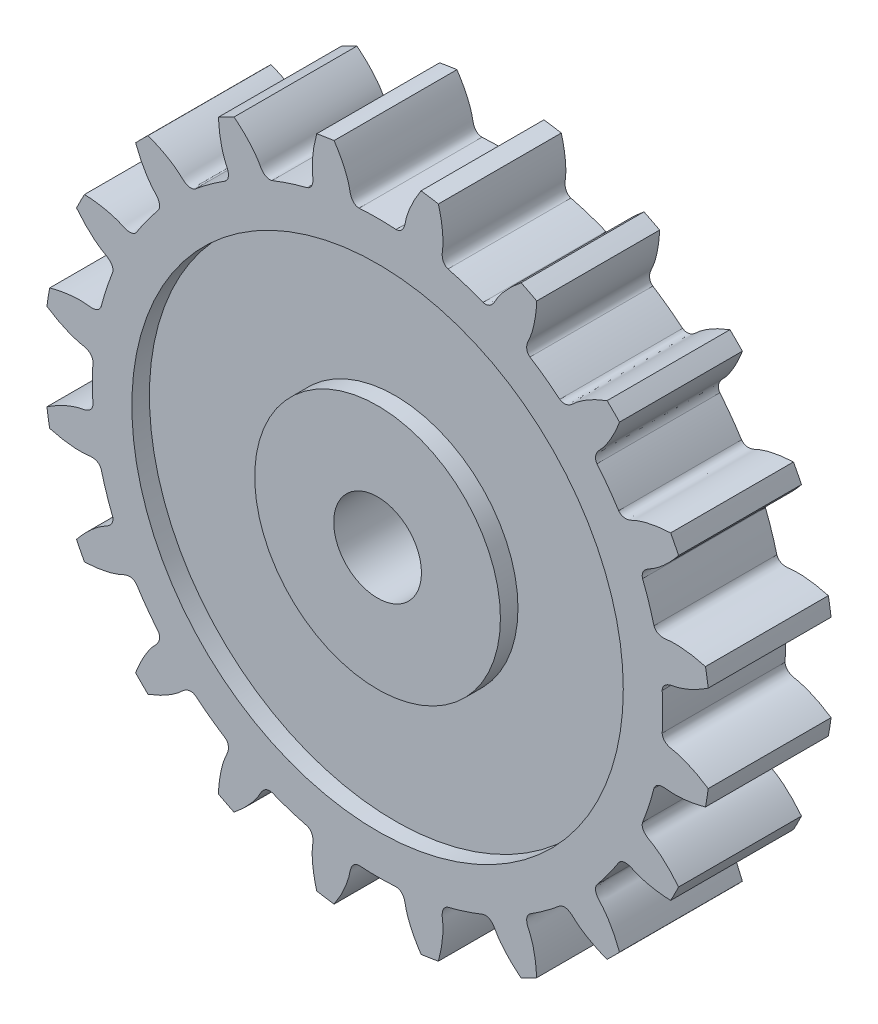
from build123d import *

# Parameters (mm, degrees)
CROQUIS1_R              = 2.5
SALIENTE_EXTRUIR1_DEPTH = 7
CROQUIS2_R              = 14
CROQUIS2_R_2            = 7
CORTAR_EXTRUIR1_DEPTH   = 1
CROQUIS3_R              = 14
CROQUIS3_R_2            = 7
CORTAR_EXTRUIR2_DEPTH   = 1


with BuildPart() as part:
    # Croquis1 → Saliente-Extruir1 (new body)
    with BuildSketch(Plane.XY):
        with BuildLine():
            ThreePointArc((6.009338484, 15.098024738), (5.021526159, 15.45466839), (4.012739321, 15.746759131))
            add(Edge.make_bspline(
                [(4.012739321, 15.746759131), (3.946115444, 15.769102329), (3.844071312, 15.832245409), (3.753150436, 15.958574818), (3.709049528, 16.068220448), (3.687336313, 16.171871712), (3.679630722, 16.27329844), (3.681699682, 16.352274965), (3.686361582, 16.409563995), (3.690140505, 16.445010565), (3.695527746, 16.484388184), (3.704084221, 16.544422236), (3.713446112, 16.632533556), (3.721941557, 16.752412041), (3.726649101, 16.89437231), (3.726023288, 17.058257781), (3.718404355, 17.243841257), (3.702184036, 17.450797585), (3.675756229, 17.678713454), (3.637539698, 17.927084936), (3.572554469, 18.265123942), (3.510335789, 18.518138446), (3.465069654, 18.681362164)],
                knots=[0.032345382, 0.032345382, 0.032345382, 0.032345382, 0.098318952, 0.140640605, 0.17619302, 0.208307484, 0.239484432, 0.271287113, 0.282206678, 0.293329329, 0.304676551, 0.319437818, 0.350137192, 0.387658647, 0.432002182, 0.483167798, 0.541155495, 0.605965273, 0.677597132, 0.756051072, 0.841327094, 1, 1, 1, 1], degree=3))
            ThreePointArc((3.465069654, 18.681362164), (2.972254836, 18.766078471), (2.477381313, 18.837796629))
            add(Edge.make_bspline(
                [(2.477381313, 18.837796629), (2.383891758, 18.696549653), (2.246532494, 18.47514519), (2.080268072, 18.173732531), (1.967170982, 17.949326772), (1.871606768, 17.740732541), (1.792227304, 17.548917731), (1.727632821, 17.374771737), (1.676394242, 17.219100778), (1.637003247, 17.082633828), (1.608038406, 16.965997377), (1.589714197, 16.879305549), (1.579300347, 16.819565676), (1.572255564, 16.780450587), (1.564895941, 16.745571144), (1.551626388, 16.689645432), (1.529188997, 16.613894949), (1.490517962, 16.519813557), (1.437837465, 16.427945099), (1.362012645, 16.337293839), (1.23650382, 16.245243527), (1.119941798, 16.216724261), (1.049674299, 16.216062527)],
                knots=[0, 0, 0, 0, 0.158672906, 0.243948928, 0.322402868, 0.394034727, 0.458844505, 0.516832202, 0.567997818, 0.612341353, 0.649862808, 0.680562182, 0.695323449, 0.706670671, 0.717793322, 0.728712887, 0.760515568, 0.791692516, 0.82380698, 0.859359395, 0.901681048, 0.967654618, 0.967654618, 0.967654618, 0.967654618], degree=3))
            ThreePointArc((1.049674299, 16.216062527), (0, 16.25), (-1.049674299, 16.216062527))
            add(Edge.make_bspline(
                [(-1.049674299, 16.216062527), (-1.119941798, 16.216724261), (-1.23650382, 16.245243527), (-1.362012645, 16.337293839), (-1.437837465, 16.427945099), (-1.490517962, 16.519813557), (-1.529188997, 16.613894949), (-1.551626388, 16.689645432), (-1.564895941, 16.745571144), (-1.572255564, 16.780450587), (-1.579300347, 16.819565676), (-1.589714197, 16.879305549), (-1.608038406, 16.965997377), (-1.637003247, 17.082633828), (-1.676394242, 17.219100778), (-1.727632821, 17.374771737), (-1.792227304, 17.548917731), (-1.871606768, 17.740732541), (-1.967170982, 17.949326772), (-2.080268072, 18.173732531), (-2.246532494, 18.47514519), (-2.383891758, 18.696549653), (-2.477381313, 18.837796629)],
                knots=[0.032345382, 0.032345382, 0.032345382, 0.032345382, 0.098318952, 0.140640605, 0.17619302, 0.208307484, 0.239484432, 0.271287113, 0.282206678, 0.293329329, 0.304676551, 0.319437818, 0.350137192, 0.387658647, 0.432002182, 0.483167798, 0.541155495, 0.605965273, 0.677597132, 0.756051072, 0.841327094, 1, 1, 1, 1], degree=3))
            ThreePointArc((-2.477381313, 18.837796629), (-2.972254836, 18.766078471), (-3.465069654, 18.681362164))
            add(Edge.make_bspline(
                [(-3.465069654, 18.681362164), (-3.510335789, 18.518138446), (-3.572554469, 18.265123942), (-3.637539698, 17.927084936), (-3.675756229, 17.678713454), (-3.702184036, 17.450797585), (-3.718404355, 17.243841257), (-3.726023288, 17.058257781), (-3.726649101, 16.89437231), (-3.721941557, 16.752412041), (-3.713446112, 16.632533556), (-3.704084221, 16.544422236), (-3.695527746, 16.484388184), (-3.690140505, 16.445010565), (-3.686361582, 16.409563995), (-3.681699682, 16.352274965), (-3.679630722, 16.27329844), (-3.687336313, 16.171871712), (-3.709049528, 16.068220448), (-3.753150436, 15.958574818), (-3.844071312, 15.832245409), (-3.946115444, 15.769102329), (-4.012739321, 15.746759131)],
                knots=[0, 0, 0, 0, 0.158672906, 0.243948928, 0.322402868, 0.394034727, 0.458844505, 0.516832202, 0.567997818, 0.612341353, 0.649862808, 0.680562182, 0.695323449, 0.706670671, 0.717793322, 0.728712887, 0.760515568, 0.791692516, 0.82380698, 0.859359395, 0.901681048, 0.967654618, 0.967654618, 0.967654618, 0.967654618], degree=3))
            ThreePointArc((-4.012739321, 15.746759131), (-5.021526159, 15.45466839), (-6.009338484, 15.098024738))
            add(Edge.make_bspline(
                [(-6.009338484, 15.098024738), (-6.076371335, 15.076940233), (-6.196041343, 15.068044021), (-6.34385244, 15.11680471), (-6.443978909, 15.179588024), (-6.522469953, 15.25068095), (-6.588321042, 15.328207665), (-6.633068455, 15.39331712), (-6.662970546, 15.442405115), (-6.680748304, 15.473303188), (-6.699535518, 15.508326891), (-6.727900314, 15.561924829), (-6.77211692, 15.638711166), (-6.835706767, 15.740688395), (-6.915340436, 15.85830369), (-7.012176192, 15.990521978), (-7.127423268, 16.136183867), (-7.26219166, 16.294080989), (-7.417537791, 16.462934926), (-7.594444709, 16.641408562), (-7.845713205, 16.876690503), (-8.044767369, 17.044812314), (-8.177328936, 17.150256309)],
                knots=[0.032345382, 0.032345382, 0.032345382, 0.032345382, 0.098318952, 0.140640605, 0.17619302, 0.208307484, 0.239484432, 0.271287113, 0.282206678, 0.293329329, 0.304676551, 0.319437818, 0.350137192, 0.387658647, 0.432002182, 0.483167798, 0.541155495, 0.605965273, 0.677597132, 0.756051072, 0.841327094, 1, 1, 1, 1], degree=3))
            ThreePointArc((-8.177328936, 17.150256309), (-8.625819495, 16.92912396), (-9.06833546, 16.696265809))
            add(Edge.make_bspline(
                [(-9.06833546, 16.696265809), (-9.06094721, 16.527042824), (-9.04193491, 16.267185101), (-8.999279738, 15.925609363), (-8.95887481, 15.677584488), (-8.913579271, 15.452656974), (-8.865052689, 15.250817455), (-8.814950277, 15.071962702), (-8.764902064, 14.915904969), (-8.716556788, 14.782347442), (-8.671432651, 14.670961465), (-8.635301069, 14.590055603), (-8.608611834, 14.535603923), (-8.591319911, 14.499818331), (-8.576772349, 14.467274391), (-8.554635334, 14.414229892), (-8.528262548, 14.339758097), (-8.504248418, 14.240914387), (-8.49286891, 14.135626425), (-8.500929004, 14.017719304), (-8.548361961, 13.869476801), (-8.625899413, 13.777890793), (-8.682358057, 13.736053238)],
                knots=[0, 0, 0, 0, 0.158672906, 0.243948928, 0.322402868, 0.394034727, 0.458844505, 0.516832202, 0.567997818, 0.612341353, 0.649862808, 0.680562182, 0.695323449, 0.706670671, 0.717793322, 0.728712887, 0.760515568, 0.791692516, 0.82380698, 0.859359395, 0.901681048, 0.967654618, 0.967654618, 0.967654618, 0.967654618], degree=3))
            ThreePointArc((-8.682358057, 13.736053238), (-9.55151035, 13.146526159), (-10.38076675, 12.502087093))
            add(Edge.make_bspline(
                [(-10.38076675, 12.502087093), (-10.438003309, 12.461320247), (-10.549067169, 12.415879381), (-10.704711757, 12.416577411), (-10.819338799, 12.445347111), (-10.915957141, 12.488705435), (-11.00254232, 12.542088616), (-11.065219567, 12.590183677), (-11.10882717, 12.62762888), (-11.135282852, 12.651521064), (-11.163973475, 12.679025017), (-11.207512672, 12.721234482), (-11.273293447, 12.780598945), (-11.365283681, 12.857934709), (-11.477364926, 12.945185345), (-11.610318901, 13.041008515), (-11.764937383, 13.143927899), (-11.941902634, 13.252451262), (-12.141824321, 13.365036305), (-12.365224184, 13.480107575), (-12.676900843, 13.626227763), (-12.9181651, 13.724609987), (-13.076822628, 13.783929409)],
                knots=[0.032345382, 0.032345382, 0.032345382, 0.032345382, 0.098318952, 0.140640605, 0.17619302, 0.208307484, 0.239484432, 0.271287113, 0.282206678, 0.293329329, 0.304676551, 0.319437818, 0.350137192, 0.387658647, 0.432002182, 0.483167798, 0.541155495, 0.605965273, 0.677597132, 0.756051072, 0.841327094, 1, 1, 1, 1], degree=3))
            ThreePointArc((-13.076822628, 13.783929409), (-13.435028843, 13.435028843), (-13.783929409, 13.076822628))
            add(Edge.make_bspline(
                [(-13.783929409, 13.076822628), (-13.724609987, 12.9181651), (-13.626227763, 12.676900843), (-13.480107575, 12.365224184), (-13.365036305, 12.141824321), (-13.252451262, 11.941902634), (-13.143927899, 11.764937383), (-13.041008515, 11.610318901), (-12.945185345, 11.477364926), (-12.857934709, 11.365283681), (-12.780598945, 11.273293447), (-12.721234482, 11.207512672), (-12.679025017, 11.163973475), (-12.651521064, 11.135282852), (-12.62762888, 11.10882717), (-12.590183677, 11.065219567), (-12.542088616, 11.00254232), (-12.488705435, 10.915957141), (-12.445347111, 10.819338799), (-12.416577411, 10.704711757), (-12.415879381, 10.549067169), (-12.461320247, 10.438003309), (-12.502087093, 10.38076675)],
                knots=[0, 0, 0, 0, 0.158672906, 0.243948928, 0.322402868, 0.394034727, 0.458844505, 0.516832202, 0.567997818, 0.612341353, 0.649862808, 0.680562182, 0.695323449, 0.706670671, 0.717793322, 0.728712887, 0.760515568, 0.791692516, 0.82380698, 0.859359395, 0.901681048, 0.967654618, 0.967654618, 0.967654618, 0.967654618], degree=3))
            ThreePointArc((-12.502087093, 10.38076675), (-13.146526159, 9.55151035), (-13.736053238, 8.682358057))
            add(Edge.make_bspline(
                [(-13.736053238, 8.682358057), (-13.777890793, 8.625899413), (-13.869476801, 8.548361961), (-14.017719304, 8.500929004), (-14.135626425, 8.49286891), (-14.240914387, 8.504248418), (-14.339758097, 8.528262548), (-14.414229892, 8.554635334), (-14.467274391, 8.576772349), (-14.499818331, 8.591319911), (-14.535603923, 8.608611834), (-14.590055603, 8.635301069), (-14.670961465, 8.671432651), (-14.782347442, 8.716556788), (-14.915904969, 8.764902064), (-15.071962702, 8.814950277), (-15.250817455, 8.865052689), (-15.452656974, 8.913579271), (-15.677584488, 8.95887481), (-15.925609363, 8.999279738), (-16.267185101, 9.04193491), (-16.527042824, 9.06094721), (-16.696265809, 9.06833546)],
                knots=[0.032345382, 0.032345382, 0.032345382, 0.032345382, 0.098318952, 0.140640605, 0.17619302, 0.208307484, 0.239484432, 0.271287113, 0.282206678, 0.293329329, 0.304676551, 0.319437818, 0.350137192, 0.387658647, 0.432002182, 0.483167798, 0.541155495, 0.605965273, 0.677597132, 0.756051072, 0.841327094, 1, 1, 1, 1], degree=3))
            ThreePointArc((-16.696265809, 9.06833546), (-16.92912396, 8.625819495), (-17.150256309, 8.177328936))
            add(Edge.make_bspline(
                [(-17.150256309, 8.177328936), (-17.044812314, 8.044767369), (-16.876690503, 7.845713205), (-16.641408562, 7.594444709), (-16.462934926, 7.417537791), (-16.294080989, 7.26219166), (-16.136183867, 7.127423268), (-15.990521978, 7.012176192), (-15.85830369, 6.915340436), (-15.740688395, 6.835706767), (-15.638711166, 6.77211692), (-15.561924829, 6.727900314), (-15.508326891, 6.699535518), (-15.473303188, 6.680748304), (-15.442405115, 6.662970546), (-15.39331712, 6.633068455), (-15.328207665, 6.588321042), (-15.25068095, 6.522469953), (-15.179588024, 6.443978909), (-15.11680471, 6.34385244), (-15.068044021, 6.196041343), (-15.076940233, 6.076371335), (-15.098024738, 6.009338484)],
                knots=[0, 0, 0, 0, 0.158672906, 0.243948928, 0.322402868, 0.394034727, 0.458844505, 0.516832202, 0.567997818, 0.612341353, 0.649862808, 0.680562182, 0.695323449, 0.706670671, 0.717793322, 0.728712887, 0.760515568, 0.791692516, 0.82380698, 0.859359395, 0.901681048, 0.967654618, 0.967654618, 0.967654618, 0.967654618], degree=3))
            ThreePointArc((-15.098024738, 6.009338484), (-15.45466839, 5.021526159), (-15.746759131, 4.012739321))
            add(Edge.make_bspline(
                [(-15.746759131, 4.012739321), (-15.769102329, 3.946115444), (-15.832245409, 3.844071312), (-15.958574818, 3.753150436), (-16.068220448, 3.709049528), (-16.171871712, 3.687336313), (-16.27329844, 3.679630722), (-16.352274965, 3.681699682), (-16.409563995, 3.686361582), (-16.445010565, 3.690140505), (-16.484388184, 3.695527746), (-16.544422236, 3.704084221), (-16.632533556, 3.713446112), (-16.752412041, 3.721941557), (-16.89437231, 3.726649101), (-17.058257781, 3.726023288), (-17.243841257, 3.718404355), (-17.450797585, 3.702184036), (-17.678713454, 3.675756229), (-17.927084936, 3.637539698), (-18.265123942, 3.572554469), (-18.518138446, 3.510335789), (-18.681362164, 3.465069654)],
                knots=[0.032345382, 0.032345382, 0.032345382, 0.032345382, 0.098318952, 0.140640605, 0.17619302, 0.208307484, 0.239484432, 0.271287113, 0.282206678, 0.293329329, 0.304676551, 0.319437818, 0.350137192, 0.387658647, 0.432002182, 0.483167798, 0.541155495, 0.605965273, 0.677597132, 0.756051072, 0.841327094, 1, 1, 1, 1], degree=3))
            ThreePointArc((-18.681362164, 3.465069654), (-18.766078471, 2.972254836), (-18.837796629, 2.477381313))
            add(Edge.make_bspline(
                [(-18.837796629, 2.477381313), (-18.696549653, 2.383891758), (-18.47514519, 2.246532494), (-18.173732531, 2.080268072), (-17.949326772, 1.967170982), (-17.740732541, 1.871606768), (-17.548917731, 1.792227304), (-17.374771737, 1.727632821), (-17.219100778, 1.676394242), (-17.082633828, 1.637003247), (-16.965997377, 1.608038406), (-16.879305549, 1.589714197), (-16.819565676, 1.579300347), (-16.780450587, 1.572255564), (-16.745571144, 1.564895941), (-16.689645432, 1.551626388), (-16.613894949, 1.529188997), (-16.519813557, 1.490517962), (-16.427945099, 1.437837465), (-16.337293839, 1.362012645), (-16.245243527, 1.23650382), (-16.216724261, 1.119941798), (-16.216062527, 1.049674299)],
                knots=[0, 0, 0, 0, 0.158672906, 0.243948928, 0.322402868, 0.394034727, 0.458844505, 0.516832202, 0.567997818, 0.612341353, 0.649862808, 0.680562182, 0.695323449, 0.706670671, 0.717793322, 0.728712887, 0.760515568, 0.791692516, 0.82380698, 0.859359395, 0.901681048, 0.967654618, 0.967654618, 0.967654618, 0.967654618], degree=3))
            ThreePointArc((-16.216062527, 1.049674299), (-16.25, 0), (-16.216062527, -1.049674299))
            add(Edge.make_bspline(
                [(-16.216062527, -1.049674299), (-16.216724261, -1.119941798), (-16.245243527, -1.23650382), (-16.337293839, -1.362012645), (-16.427945099, -1.437837465), (-16.519813557, -1.490517962), (-16.613894949, -1.529188997), (-16.689645432, -1.551626388), (-16.745571144, -1.564895941), (-16.780450587, -1.572255564), (-16.819565676, -1.579300347), (-16.879305549, -1.589714197), (-16.965997377, -1.608038406), (-17.082633828, -1.637003247), (-17.219100778, -1.676394242), (-17.374771737, -1.727632821), (-17.548917731, -1.792227304), (-17.740732541, -1.871606768), (-17.949326772, -1.967170982), (-18.173732531, -2.080268072), (-18.47514519, -2.246532494), (-18.696549653, -2.383891758), (-18.837796629, -2.477381313)],
                knots=[0.032345382, 0.032345382, 0.032345382, 0.032345382, 0.098318952, 0.140640605, 0.17619302, 0.208307484, 0.239484432, 0.271287113, 0.282206678, 0.293329329, 0.304676551, 0.319437818, 0.350137192, 0.387658647, 0.432002182, 0.483167798, 0.541155495, 0.605965273, 0.677597132, 0.756051072, 0.841327094, 1, 1, 1, 1], degree=3))
            ThreePointArc((-18.837796629, -2.477381313), (-18.766078471, -2.972254836), (-18.681362164, -3.465069654))
            add(Edge.make_bspline(
                [(-18.681362164, -3.465069654), (-18.518138446, -3.510335789), (-18.265123942, -3.572554469), (-17.927084936, -3.637539698), (-17.678713454, -3.675756229), (-17.450797585, -3.702184036), (-17.243841257, -3.718404355), (-17.058257781, -3.726023288), (-16.89437231, -3.726649101), (-16.752412041, -3.721941557), (-16.632533556, -3.713446112), (-16.544422236, -3.704084221), (-16.484388184, -3.695527746), (-16.445010565, -3.690140505), (-16.409563995, -3.686361582), (-16.352274965, -3.681699682), (-16.27329844, -3.679630722), (-16.171871712, -3.687336313), (-16.068220448, -3.709049528), (-15.958574818, -3.753150436), (-15.832245409, -3.844071312), (-15.769102329, -3.946115444), (-15.746759131, -4.012739321)],
                knots=[0, 0, 0, 0, 0.158672906, 0.243948928, 0.322402868, 0.394034727, 0.458844505, 0.516832202, 0.567997818, 0.612341353, 0.649862808, 0.680562182, 0.695323449, 0.706670671, 0.717793322, 0.728712887, 0.760515568, 0.791692516, 0.82380698, 0.859359395, 0.901681048, 0.967654618, 0.967654618, 0.967654618, 0.967654618], degree=3))
            ThreePointArc((-15.746759131, -4.012739321), (-15.45466839, -5.021526159), (-15.098024738, -6.009338484))
            add(Edge.make_bspline(
                [(-15.098024738, -6.009338484), (-15.076940233, -6.076371335), (-15.068044021, -6.196041343), (-15.11680471, -6.34385244), (-15.179588024, -6.443978909), (-15.25068095, -6.522469953), (-15.328207665, -6.588321042), (-15.39331712, -6.633068455), (-15.442405115, -6.662970546), (-15.473303188, -6.680748304), (-15.508326891, -6.699535518), (-15.561924829, -6.727900314), (-15.638711166, -6.77211692), (-15.740688395, -6.835706767), (-15.85830369, -6.915340436), (-15.990521978, -7.012176192), (-16.136183867, -7.127423268), (-16.294080989, -7.26219166), (-16.462934926, -7.417537791), (-16.641408562, -7.594444709), (-16.876690503, -7.845713205), (-17.044812314, -8.044767369), (-17.150256309, -8.177328936)],
                knots=[0.032345382, 0.032345382, 0.032345382, 0.032345382, 0.098318952, 0.140640605, 0.17619302, 0.208307484, 0.239484432, 0.271287113, 0.282206678, 0.293329329, 0.304676551, 0.319437818, 0.350137192, 0.387658647, 0.432002182, 0.483167798, 0.541155495, 0.605965273, 0.677597132, 0.756051072, 0.841327094, 1, 1, 1, 1], degree=3))
            ThreePointArc((-17.150256309, -8.177328936), (-16.92912396, -8.625819495), (-16.696265809, -9.06833546))
            add(Edge.make_bspline(
                [(-16.696265809, -9.06833546), (-16.527042824, -9.06094721), (-16.267185101, -9.04193491), (-15.925609363, -8.999279738), (-15.677584488, -8.95887481), (-15.452656974, -8.913579271), (-15.250817455, -8.865052689), (-15.071962702, -8.814950277), (-14.915904969, -8.764902064), (-14.782347442, -8.716556788), (-14.670961465, -8.671432651), (-14.590055603, -8.635301069), (-14.535603923, -8.608611834), (-14.499818331, -8.591319911), (-14.467274391, -8.576772349), (-14.414229892, -8.554635334), (-14.339758097, -8.528262548), (-14.240914387, -8.504248418), (-14.135626425, -8.49286891), (-14.017719304, -8.500929004), (-13.869476801, -8.548361961), (-13.777890793, -8.625899413), (-13.736053238, -8.682358057)],
                knots=[0, 0, 0, 0, 0.158672906, 0.243948928, 0.322402868, 0.394034727, 0.458844505, 0.516832202, 0.567997818, 0.612341353, 0.649862808, 0.680562182, 0.695323449, 0.706670671, 0.717793322, 0.728712887, 0.760515568, 0.791692516, 0.82380698, 0.859359395, 0.901681048, 0.967654618, 0.967654618, 0.967654618, 0.967654618], degree=3))
            ThreePointArc((-13.736053238, -8.682358057), (-13.146526159, -9.55151035), (-12.502087093, -10.38076675))
            add(Edge.make_bspline(
                [(-12.502087093, -10.38076675), (-12.461320247, -10.438003309), (-12.415879381, -10.549067169), (-12.416577411, -10.704711757), (-12.445347111, -10.819338799), (-12.488705435, -10.915957141), (-12.542088616, -11.00254232), (-12.590183677, -11.065219567), (-12.62762888, -11.10882717), (-12.651521064, -11.135282852), (-12.679025017, -11.163973475), (-12.721234482, -11.207512672), (-12.780598945, -11.273293447), (-12.857934709, -11.365283681), (-12.945185345, -11.477364926), (-13.041008515, -11.610318901), (-13.143927899, -11.764937383), (-13.252451262, -11.941902634), (-13.365036305, -12.141824321), (-13.480107575, -12.365224184), (-13.626227763, -12.676900843), (-13.724609987, -12.9181651), (-13.783929409, -13.076822628)],
                knots=[0.032345382, 0.032345382, 0.032345382, 0.032345382, 0.098318952, 0.140640605, 0.17619302, 0.208307484, 0.239484432, 0.271287113, 0.282206678, 0.293329329, 0.304676551, 0.319437818, 0.350137192, 0.387658647, 0.432002182, 0.483167798, 0.541155495, 0.605965273, 0.677597132, 0.756051072, 0.841327094, 1, 1, 1, 1], degree=3))
            ThreePointArc((-13.783929409, -13.076822628), (-13.435028843, -13.435028843), (-13.076822628, -13.783929409))
            add(Edge.make_bspline(
                [(-13.076822628, -13.783929409), (-12.9181651, -13.724609987), (-12.676900843, -13.626227763), (-12.365224184, -13.480107575), (-12.141824321, -13.365036305), (-11.941902634, -13.252451262), (-11.764937383, -13.143927899), (-11.610318901, -13.041008515), (-11.477364926, -12.945185345), (-11.365283681, -12.857934709), (-11.273293447, -12.780598945), (-11.207512672, -12.721234482), (-11.163973475, -12.679025017), (-11.135282852, -12.651521064), (-11.10882717, -12.62762888), (-11.065219567, -12.590183677), (-11.00254232, -12.542088616), (-10.915957141, -12.488705435), (-10.819338799, -12.445347111), (-10.704711757, -12.416577411), (-10.549067169, -12.415879381), (-10.438003309, -12.461320247), (-10.38076675, -12.502087093)],
                knots=[0, 0, 0, 0, 0.158672906, 0.243948928, 0.322402868, 0.394034727, 0.458844505, 0.516832202, 0.567997818, 0.612341353, 0.649862808, 0.680562182, 0.695323449, 0.706670671, 0.717793322, 0.728712887, 0.760515568, 0.791692516, 0.82380698, 0.859359395, 0.901681048, 0.967654618, 0.967654618, 0.967654618, 0.967654618], degree=3))
            ThreePointArc((-10.38076675, -12.502087093), (-9.55151035, -13.146526159), (-8.682358057, -13.736053238))
            add(Edge.make_bspline(
                [(-8.682358057, -13.736053238), (-8.625899413, -13.777890793), (-8.548361961, -13.869476801), (-8.500929004, -14.017719304), (-8.49286891, -14.135626425), (-8.504248418, -14.240914387), (-8.528262548, -14.339758097), (-8.554635334, -14.414229892), (-8.576772349, -14.467274391), (-8.591319911, -14.499818331), (-8.608611834, -14.535603923), (-8.635301069, -14.590055603), (-8.671432651, -14.670961465), (-8.716556788, -14.782347442), (-8.764902064, -14.915904969), (-8.814950277, -15.071962702), (-8.865052689, -15.250817455), (-8.913579271, -15.452656974), (-8.95887481, -15.677584488), (-8.999279738, -15.925609363), (-9.04193491, -16.267185101), (-9.06094721, -16.527042824), (-9.06833546, -16.696265809)],
                knots=[0.032345382, 0.032345382, 0.032345382, 0.032345382, 0.098318952, 0.140640605, 0.17619302, 0.208307484, 0.239484432, 0.271287113, 0.282206678, 0.293329329, 0.304676551, 0.319437818, 0.350137192, 0.387658647, 0.432002182, 0.483167798, 0.541155495, 0.605965273, 0.677597132, 0.756051072, 0.841327094, 1, 1, 1, 1], degree=3))
            ThreePointArc((-9.06833546, -16.696265809), (-8.625819495, -16.92912396), (-8.177328936, -17.150256309))
            add(Edge.make_bspline(
                [(-8.177328936, -17.150256309), (-8.044767369, -17.044812314), (-7.845713205, -16.876690503), (-7.594444709, -16.641408562), (-7.417537791, -16.462934926), (-7.26219166, -16.294080989), (-7.127423268, -16.136183867), (-7.012176192, -15.990521978), (-6.915340436, -15.85830369), (-6.835706767, -15.740688395), (-6.77211692, -15.638711166), (-6.727900314, -15.561924829), (-6.699535518, -15.508326891), (-6.680748304, -15.473303188), (-6.662970546, -15.442405115), (-6.633068455, -15.39331712), (-6.588321042, -15.328207665), (-6.522469953, -15.25068095), (-6.443978909, -15.179588024), (-6.34385244, -15.11680471), (-6.196041343, -15.068044021), (-6.076371335, -15.076940233), (-6.009338484, -15.098024738)],
                knots=[0, 0, 0, 0, 0.158672906, 0.243948928, 0.322402868, 0.394034727, 0.458844505, 0.516832202, 0.567997818, 0.612341353, 0.649862808, 0.680562182, 0.695323449, 0.706670671, 0.717793322, 0.728712887, 0.760515568, 0.791692516, 0.82380698, 0.859359395, 0.901681048, 0.967654618, 0.967654618, 0.967654618, 0.967654618], degree=3))
            ThreePointArc((-6.009338484, -15.098024738), (-5.021526159, -15.45466839), (-4.012739321, -15.746759131))
            add(Edge.make_bspline(
                [(-4.012739321, -15.746759131), (-3.946115444, -15.769102329), (-3.844071312, -15.832245409), (-3.753150437, -15.958574818), (-3.709049528, -16.068220448), (-3.687336313, -16.171871712), (-3.679630722, -16.27329844), (-3.681699682, -16.352274965), (-3.686361582, -16.409563995), (-3.690140505, -16.445010565), (-3.695527746, -16.484388184), (-3.704084221, -16.544422236), (-3.713446112, -16.632533556), (-3.721941557, -16.752412041), (-3.726649101, -16.89437231), (-3.726023288, -17.058257781), (-3.718404355, -17.243841257), (-3.702184036, -17.450797585), (-3.675756229, -17.678713454), (-3.637539698, -17.927084936), (-3.572554469, -18.265123942), (-3.510335789, -18.518138446), (-3.465069654, -18.681362164)],
                knots=[0.032345382, 0.032345382, 0.032345382, 0.032345382, 0.098318952, 0.140640605, 0.17619302, 0.208307484, 0.239484432, 0.271287113, 0.282206678, 0.293329329, 0.304676551, 0.319437818, 0.350137192, 0.387658647, 0.432002182, 0.483167798, 0.541155495, 0.605965273, 0.677597132, 0.756051072, 0.841327094, 1, 1, 1, 1], degree=3))
            ThreePointArc((-3.465069654, -18.681362164), (-2.972254836, -18.766078471), (-2.477381313, -18.837796629))
            add(Edge.make_bspline(
                [(-2.477381313, -18.837796629), (-2.383891758, -18.696549653), (-2.246532494, -18.47514519), (-2.080268072, -18.173732531), (-1.967170982, -17.949326772), (-1.871606768, -17.740732541), (-1.792227304, -17.548917731), (-1.727632821, -17.374771737), (-1.676394242, -17.219100778), (-1.637003247, -17.082633828), (-1.608038406, -16.965997377), (-1.589714197, -16.879305549), (-1.579300347, -16.819565676), (-1.572255564, -16.780450587), (-1.564895941, -16.745571144), (-1.551626388, -16.689645432), (-1.529188997, -16.613894949), (-1.490517962, -16.519813557), (-1.437837465, -16.427945099), (-1.362012645, -16.337293839), (-1.23650382, -16.245243527), (-1.119941798, -16.216724261), (-1.049674299, -16.216062527)],
                knots=[0, 0, 0, 0, 0.158672906, 0.243948928, 0.322402868, 0.394034727, 0.458844505, 0.516832202, 0.567997818, 0.612341353, 0.649862808, 0.680562182, 0.695323449, 0.706670671, 0.717793322, 0.728712887, 0.760515568, 0.791692516, 0.82380698, 0.859359395, 0.901681048, 0.967654618, 0.967654618, 0.967654618, 0.967654618], degree=3))
            ThreePointArc((-1.049674299, -16.216062527), (0, -16.25), (1.049674299, -16.216062527))
            add(Edge.make_bspline(
                [(1.049674299, -16.216062527), (1.119941798, -16.216724261), (1.23650382, -16.245243527), (1.362012645, -16.337293839), (1.437837465, -16.427945099), (1.490517962, -16.519813557), (1.529188997, -16.613894949), (1.551626388, -16.689645432), (1.564895941, -16.745571144), (1.572255564, -16.780450587), (1.579300347, -16.819565676), (1.589714197, -16.879305549), (1.608038406, -16.965997377), (1.637003247, -17.082633828), (1.676394242, -17.219100778), (1.727632821, -17.374771737), (1.792227304, -17.548917731), (1.871606768, -17.740732541), (1.967170982, -17.949326772), (2.080268072, -18.173732531), (2.246532494, -18.47514519), (2.383891758, -18.696549653), (2.477381313, -18.837796629)],
                knots=[0.032345382, 0.032345382, 0.032345382, 0.032345382, 0.098318952, 0.140640605, 0.17619302, 0.208307484, 0.239484432, 0.271287113, 0.282206678, 0.293329329, 0.304676551, 0.319437818, 0.350137192, 0.387658647, 0.432002182, 0.483167798, 0.541155495, 0.605965273, 0.677597132, 0.756051072, 0.841327094, 1, 1, 1, 1], degree=3))
            ThreePointArc((2.477381313, -18.837796629), (2.972254836, -18.766078471), (3.465069654, -18.681362164))
            add(Edge.make_bspline(
                [(3.465069654, -18.681362164), (3.510335789, -18.518138446), (3.572554469, -18.265123942), (3.637539698, -17.927084936), (3.675756229, -17.678713454), (3.702184036, -17.450797585), (3.718404355, -17.243841257), (3.726023288, -17.058257781), (3.726649101, -16.89437231), (3.721941557, -16.752412041), (3.713446112, -16.632533556), (3.704084221, -16.544422236), (3.695527746, -16.484388184), (3.690140505, -16.445010565), (3.686361582, -16.409563995), (3.681699682, -16.352274965), (3.679630722, -16.27329844), (3.687336313, -16.171871712), (3.709049528, -16.068220448), (3.753150436, -15.958574818), (3.844071312, -15.832245409), (3.946115444, -15.769102329), (4.012739321, -15.746759131)],
                knots=[0, 0, 0, 0, 0.158672906, 0.243948928, 0.322402868, 0.394034727, 0.458844505, 0.516832202, 0.567997818, 0.612341353, 0.649862808, 0.680562182, 0.695323449, 0.706670671, 0.717793322, 0.728712887, 0.760515568, 0.791692516, 0.82380698, 0.859359395, 0.901681048, 0.967654618, 0.967654618, 0.967654618, 0.967654618], degree=3))
            ThreePointArc((4.012739321, -15.746759131), (5.021526159, -15.45466839), (6.009338484, -15.098024738))
            add(Edge.make_bspline(
                [(6.009338484, -15.098024738), (6.076371335, -15.076940233), (6.196041343, -15.068044021), (6.34385244, -15.11680471), (6.443978909, -15.179588024), (6.522469953, -15.25068095), (6.588321042, -15.328207665), (6.633068455, -15.39331712), (6.662970546, -15.442405115), (6.680748304, -15.473303188), (6.699535518, -15.508326891), (6.727900314, -15.561924829), (6.77211692, -15.638711166), (6.835706767, -15.740688395), (6.915340436, -15.85830369), (7.012176192, -15.990521978), (7.127423268, -16.136183867), (7.26219166, -16.294080989), (7.417537791, -16.462934926), (7.594444709, -16.641408562), (7.845713205, -16.876690503), (8.044767369, -17.044812314), (8.177328936, -17.150256309)],
                knots=[0.032345382, 0.032345382, 0.032345382, 0.032345382, 0.098318952, 0.140640605, 0.17619302, 0.208307484, 0.239484432, 0.271287113, 0.282206678, 0.293329329, 0.304676551, 0.319437818, 0.350137192, 0.387658647, 0.432002182, 0.483167798, 0.541155495, 0.605965273, 0.677597132, 0.756051072, 0.841327094, 1, 1, 1, 1], degree=3))
            ThreePointArc((8.177328936, -17.150256309), (8.625819495, -16.92912396), (9.06833546, -16.696265809))
            add(Edge.make_bspline(
                [(9.06833546, -16.696265809), (9.06094721, -16.527042824), (9.04193491, -16.267185101), (8.999279738, -15.925609363), (8.95887481, -15.677584488), (8.913579271, -15.452656974), (8.865052689, -15.250817455), (8.814950277, -15.071962702), (8.764902064, -14.915904969), (8.716556788, -14.782347442), (8.671432651, -14.670961465), (8.635301069, -14.590055603), (8.608611834, -14.535603923), (8.591319911, -14.499818331), (8.576772349, -14.467274391), (8.554635334, -14.414229892), (8.528262548, -14.339758097), (8.504248418, -14.240914387), (8.49286891, -14.135626425), (8.500929004, -14.017719304), (8.548361961, -13.869476801), (8.625899413, -13.777890793), (8.682358057, -13.736053238)],
                knots=[0, 0, 0, 0, 0.158672906, 0.243948928, 0.322402868, 0.394034727, 0.458844505, 0.516832202, 0.567997818, 0.612341353, 0.649862808, 0.680562182, 0.695323449, 0.706670671, 0.717793322, 0.728712887, 0.760515568, 0.791692516, 0.82380698, 0.859359395, 0.901681048, 0.967654618, 0.967654618, 0.967654618, 0.967654618], degree=3))
            ThreePointArc((8.682358057, -13.736053238), (9.55151035, -13.146526159), (10.38076675, -12.502087093))
            add(Edge.make_bspline(
                [(10.38076675, -12.502087093), (10.438003309, -12.461320247), (10.549067169, -12.415879381), (10.704711757, -12.416577411), (10.819338799, -12.445347111), (10.915957141, -12.488705435), (11.00254232, -12.542088616), (11.065219567, -12.590183677), (11.10882717, -12.62762888), (11.135282852, -12.651521064), (11.163973475, -12.679025017), (11.207512672, -12.721234482), (11.273293447, -12.780598945), (11.365283681, -12.857934709), (11.477364926, -12.945185345), (11.610318901, -13.041008515), (11.764937383, -13.143927899), (11.941902634, -13.252451262), (12.141824321, -13.365036305), (12.365224184, -13.480107575), (12.676900843, -13.626227763), (12.9181651, -13.724609987), (13.076822628, -13.783929409)],
                knots=[0.032345382, 0.032345382, 0.032345382, 0.032345382, 0.098318952, 0.140640605, 0.17619302, 0.208307484, 0.239484432, 0.271287113, 0.282206678, 0.293329329, 0.304676551, 0.319437818, 0.350137192, 0.387658647, 0.432002182, 0.483167798, 0.541155495, 0.605965273, 0.677597132, 0.756051072, 0.841327094, 1, 1, 1, 1], degree=3))
            ThreePointArc((13.076822628, -13.783929409), (13.435028843, -13.435028843), (13.783929409, -13.076822628))
            add(Edge.make_bspline(
                [(13.783929409, -13.076822628), (13.724609987, -12.9181651), (13.626227763, -12.676900843), (13.480107575, -12.365224184), (13.365036305, -12.141824321), (13.252451262, -11.941902634), (13.143927899, -11.764937383), (13.041008515, -11.610318901), (12.945185345, -11.477364926), (12.857934709, -11.365283681), (12.780598945, -11.273293447), (12.721234482, -11.207512672), (12.679025017, -11.163973475), (12.651521064, -11.135282852), (12.62762888, -11.10882717), (12.590183677, -11.065219567), (12.542088616, -11.00254232), (12.488705435, -10.915957141), (12.445347111, -10.819338799), (12.416577411, -10.704711757), (12.415879381, -10.549067169), (12.461320247, -10.438003309), (12.502087093, -10.38076675)],
                knots=[0, 0, 0, 0, 0.158672906, 0.243948928, 0.322402868, 0.394034727, 0.458844505, 0.516832202, 0.567997818, 0.612341353, 0.649862808, 0.680562182, 0.695323449, 0.706670671, 0.717793322, 0.728712887, 0.760515568, 0.791692516, 0.82380698, 0.859359395, 0.901681048, 0.967654618, 0.967654618, 0.967654618, 0.967654618], degree=3))
            ThreePointArc((12.502087093, -10.38076675), (13.146526159, -9.55151035), (13.736053238, -8.682358057))
            add(Edge.make_bspline(
                [(13.736053238, -8.682358057), (13.777890793, -8.625899413), (13.869476801, -8.548361961), (14.017719304, -8.500929004), (14.135626425, -8.49286891), (14.240914387, -8.504248418), (14.339758097, -8.528262548), (14.414229892, -8.554635334), (14.467274391, -8.576772349), (14.499818331, -8.591319911), (14.535603923, -8.608611834), (14.590055603, -8.635301069), (14.670961465, -8.671432651), (14.782347442, -8.716556788), (14.915904969, -8.764902064), (15.071962702, -8.814950277), (15.250817455, -8.865052689), (15.452656974, -8.913579271), (15.677584488, -8.95887481), (15.925609363, -8.999279738), (16.267185101, -9.04193491), (16.527042824, -9.06094721), (16.696265809, -9.06833546)],
                knots=[0.032345382, 0.032345382, 0.032345382, 0.032345382, 0.098318952, 0.140640605, 0.17619302, 0.208307484, 0.239484432, 0.271287113, 0.282206678, 0.293329329, 0.304676551, 0.319437818, 0.350137192, 0.387658647, 0.432002182, 0.483167798, 0.541155495, 0.605965273, 0.677597132, 0.756051072, 0.841327094, 1, 1, 1, 1], degree=3))
            ThreePointArc((16.696265809, -9.06833546), (16.92912396, -8.625819495), (17.150256309, -8.177328936))
            add(Edge.make_bspline(
                [(17.150256309, -8.177328936), (17.044812314, -8.044767369), (16.876690503, -7.845713205), (16.641408562, -7.594444709), (16.462934926, -7.417537791), (16.294080989, -7.26219166), (16.136183867, -7.127423268), (15.990521978, -7.012176192), (15.85830369, -6.915340436), (15.740688395, -6.835706767), (15.638711166, -6.77211692), (15.561924829, -6.727900314), (15.508326891, -6.699535518), (15.473303188, -6.680748304), (15.442405115, -6.662970546), (15.39331712, -6.633068455), (15.328207665, -6.588321042), (15.25068095, -6.522469953), (15.179588024, -6.443978909), (15.11680471, -6.34385244), (15.068044021, -6.196041343), (15.076940233, -6.076371335), (15.098024738, -6.009338484)],
                knots=[0, 0, 0, 0, 0.158672906, 0.243948928, 0.322402868, 0.394034727, 0.458844505, 0.516832202, 0.567997818, 0.612341353, 0.649862808, 0.680562182, 0.695323449, 0.706670671, 0.717793322, 0.728712887, 0.760515568, 0.791692516, 0.82380698, 0.859359395, 0.901681048, 0.967654618, 0.967654618, 0.967654618, 0.967654618], degree=3))
            ThreePointArc((15.098024738, -6.009338484), (15.45466839, -5.021526159), (15.746759131, -4.012739321))
            add(Edge.make_bspline(
                [(15.746759131, -4.012739321), (15.769102329, -3.946115444), (15.832245409, -3.844071312), (15.958574818, -3.753150437), (16.068220448, -3.709049528), (16.171871712, -3.687336313), (16.27329844, -3.679630722), (16.352274965, -3.681699682), (16.409563995, -3.686361582), (16.445010565, -3.690140505), (16.484388184, -3.695527746), (16.544422236, -3.704084221), (16.632533556, -3.713446112), (16.752412041, -3.721941557), (16.89437231, -3.726649101), (17.058257781, -3.726023288), (17.243841257, -3.718404355), (17.450797585, -3.702184036), (17.678713454, -3.675756229), (17.927084936, -3.637539698), (18.265123942, -3.572554469), (18.518138446, -3.510335789), (18.681362164, -3.465069654)],
                knots=[0.032345382, 0.032345382, 0.032345382, 0.032345382, 0.098318952, 0.140640605, 0.17619302, 0.208307484, 0.239484432, 0.271287113, 0.282206678, 0.293329329, 0.304676551, 0.319437818, 0.350137192, 0.387658647, 0.432002182, 0.483167798, 0.541155495, 0.605965273, 0.677597132, 0.756051072, 0.841327094, 1, 1, 1, 1], degree=3))
            ThreePointArc((18.681362164, -3.465069654), (18.766078471, -2.972254836), (18.837796629, -2.477381313))
            add(Edge.make_bspline(
                [(18.837796629, -2.477381313), (18.696549653, -2.383891758), (18.47514519, -2.246532494), (18.173732531, -2.080268072), (17.949326772, -1.967170982), (17.740732541, -1.871606768), (17.548917731, -1.792227304), (17.374771737, -1.727632821), (17.219100778, -1.676394242), (17.082633828, -1.637003247), (16.965997377, -1.608038406), (16.879305549, -1.589714197), (16.819565676, -1.579300347), (16.780450587, -1.572255564), (16.745571144, -1.564895941), (16.689645432, -1.551626388), (16.613894949, -1.529188997), (16.519813557, -1.490517962), (16.427945099, -1.437837465), (16.337293839, -1.362012645), (16.245243527, -1.23650382), (16.216724261, -1.119941798), (16.216062527, -1.049674299)],
                knots=[0, 0, 0, 0, 0.158672906, 0.243948928, 0.322402868, 0.394034727, 0.458844505, 0.516832202, 0.567997818, 0.612341353, 0.649862808, 0.680562182, 0.695323449, 0.706670671, 0.717793322, 0.728712887, 0.760515568, 0.791692516, 0.82380698, 0.859359395, 0.901681048, 0.967654618, 0.967654618, 0.967654618, 0.967654618], degree=3))
            ThreePointArc((16.216062527, -1.049674299), (16.25, 0), (16.216062527, 1.049674299))
            add(Edge.make_bspline(
                [(16.216062527, 1.049674299), (16.216724261, 1.119941798), (16.245243527, 1.23650382), (16.337293839, 1.362012645), (16.427945099, 1.437837465), (16.519813557, 1.490517962), (16.613894949, 1.529188997), (16.689645432, 1.551626388), (16.745571144, 1.564895941), (16.780450587, 1.572255564), (16.819565676, 1.579300347), (16.879305549, 1.589714197), (16.965997377, 1.608038406), (17.082633828, 1.637003247), (17.219100778, 1.676394242), (17.374771737, 1.727632821), (17.548917731, 1.792227304), (17.740732541, 1.871606768), (17.949326772, 1.967170982), (18.173732531, 2.080268072), (18.47514519, 2.246532494), (18.696549653, 2.383891758), (18.837796629, 2.477381313)],
                knots=[0.032345382, 0.032345382, 0.032345382, 0.032345382, 0.098318952, 0.140640605, 0.17619302, 0.208307484, 0.239484432, 0.271287113, 0.282206678, 0.293329329, 0.304676551, 0.319437818, 0.350137192, 0.387658647, 0.432002182, 0.483167798, 0.541155495, 0.605965273, 0.677597132, 0.756051072, 0.841327094, 1, 1, 1, 1], degree=3))
            ThreePointArc((18.837796629, 2.477381313), (18.766078471, 2.972254836), (18.681362164, 3.465069654))
            add(Edge.make_bspline(
                [(18.681362164, 3.465069654), (18.518138446, 3.510335789), (18.265123942, 3.572554469), (17.927084936, 3.637539698), (17.678713454, 3.675756229), (17.450797585, 3.702184036), (17.243841257, 3.718404355), (17.058257781, 3.726023288), (16.89437231, 3.726649101), (16.752412041, 3.721941557), (16.632533556, 3.713446112), (16.544422236, 3.704084221), (16.484388184, 3.695527746), (16.445010565, 3.690140505), (16.409563995, 3.686361582), (16.352274965, 3.681699682), (16.27329844, 3.679630722), (16.171871712, 3.687336313), (16.068220448, 3.709049528), (15.958574818, 3.753150436), (15.832245409, 3.844071312), (15.769102329, 3.946115444), (15.746759131, 4.012739321)],
                knots=[0, 0, 0, 0, 0.158672906, 0.243948928, 0.322402868, 0.394034727, 0.458844505, 0.516832202, 0.567997818, 0.612341353, 0.649862808, 0.680562182, 0.695323449, 0.706670671, 0.717793322, 0.728712887, 0.760515568, 0.791692516, 0.82380698, 0.859359395, 0.901681048, 0.967654618, 0.967654618, 0.967654618, 0.967654618], degree=3))
            ThreePointArc((15.746759131, 4.012739321), (15.45466839, 5.021526159), (15.098024738, 6.009338484))
            add(Edge.make_bspline(
                [(15.098024738, 6.009338484), (15.076940233, 6.076371335), (15.068044021, 6.196041343), (15.11680471, 6.34385244), (15.179588024, 6.443978909), (15.25068095, 6.522469953), (15.328207665, 6.588321042), (15.39331712, 6.633068455), (15.442405115, 6.662970546), (15.473303188, 6.680748304), (15.508326891, 6.699535518), (15.561924829, 6.727900314), (15.638711166, 6.77211692), (15.740688395, 6.835706767), (15.85830369, 6.915340436), (15.990521978, 7.012176192), (16.136183867, 7.127423268), (16.294080989, 7.26219166), (16.462934926, 7.417537791), (16.641408562, 7.594444709), (16.876690503, 7.845713205), (17.044812314, 8.044767369), (17.150256309, 8.177328936)],
                knots=[0.032345382, 0.032345382, 0.032345382, 0.032345382, 0.098318952, 0.140640605, 0.17619302, 0.208307484, 0.239484432, 0.271287113, 0.282206678, 0.293329329, 0.304676551, 0.319437818, 0.350137192, 0.387658647, 0.432002182, 0.483167798, 0.541155495, 0.605965273, 0.677597132, 0.756051072, 0.841327094, 1, 1, 1, 1], degree=3))
            ThreePointArc((17.150256309, 8.177328936), (16.92912396, 8.625819495), (16.696265809, 9.06833546))
            add(Edge.make_bspline(
                [(16.696265809, 9.06833546), (16.527042824, 9.06094721), (16.267185101, 9.04193491), (15.925609363, 8.999279738), (15.677584488, 8.95887481), (15.452656974, 8.913579271), (15.250817455, 8.865052689), (15.071962702, 8.814950277), (14.915904969, 8.764902064), (14.782347442, 8.716556788), (14.670961465, 8.671432651), (14.590055603, 8.635301069), (14.535603923, 8.608611834), (14.499818331, 8.591319911), (14.467274391, 8.576772349), (14.414229892, 8.554635334), (14.339758097, 8.528262548), (14.240914387, 8.504248418), (14.135626425, 8.49286891), (14.017719304, 8.500929004), (13.869476801, 8.548361961), (13.777890793, 8.625899413), (13.736053238, 8.682358057)],
                knots=[0, 0, 0, 0, 0.158672906, 0.243948928, 0.322402868, 0.394034727, 0.458844505, 0.516832202, 0.567997818, 0.612341353, 0.649862808, 0.680562182, 0.695323449, 0.706670671, 0.717793322, 0.728712887, 0.760515568, 0.791692516, 0.82380698, 0.859359395, 0.901681048, 0.967654618, 0.967654618, 0.967654618, 0.967654618], degree=3))
            ThreePointArc((13.736053238, 8.682358057), (13.146526159, 9.55151035), (12.502087093, 10.38076675))
            add(Edge.make_bspline(
                [(12.502087093, 10.38076675), (12.461320247, 10.438003309), (12.415879381, 10.549067169), (12.416577411, 10.704711757), (12.445347111, 10.819338799), (12.488705435, 10.915957141), (12.542088616, 11.00254232), (12.590183677, 11.065219567), (12.62762888, 11.10882717), (12.651521064, 11.135282852), (12.679025017, 11.163973475), (12.721234482, 11.207512672), (12.780598945, 11.273293447), (12.857934709, 11.365283681), (12.945185345, 11.477364926), (13.041008515, 11.610318901), (13.143927899, 11.764937383), (13.252451262, 11.941902634), (13.365036305, 12.141824321), (13.480107575, 12.365224184), (13.626227763, 12.676900843), (13.724609987, 12.9181651), (13.783929409, 13.076822628)],
                knots=[0.032345382, 0.032345382, 0.032345382, 0.032345382, 0.098318952, 0.140640605, 0.17619302, 0.208307484, 0.239484432, 0.271287113, 0.282206678, 0.293329329, 0.304676551, 0.319437818, 0.350137192, 0.387658647, 0.432002182, 0.483167798, 0.541155495, 0.605965273, 0.677597132, 0.756051072, 0.841327094, 1, 1, 1, 1], degree=3))
            ThreePointArc((13.783929409, 13.076822628), (13.435028843, 13.435028843), (13.076822628, 13.783929409))
            add(Edge.make_bspline(
                [(13.076822628, 13.783929409), (12.9181651, 13.724609987), (12.676900843, 13.626227763), (12.365224184, 13.480107575), (12.141824321, 13.365036305), (11.941902634, 13.252451262), (11.764937383, 13.143927899), (11.610318901, 13.041008515), (11.477364926, 12.945185345), (11.365283681, 12.857934709), (11.273293447, 12.780598945), (11.207512672, 12.721234482), (11.163973475, 12.679025017), (11.135282852, 12.651521064), (11.10882717, 12.62762888), (11.065219567, 12.590183677), (11.00254232, 12.542088616), (10.915957141, 12.488705435), (10.819338799, 12.445347111), (10.704711757, 12.416577411), (10.549067169, 12.415879381), (10.438003309, 12.461320247), (10.38076675, 12.502087093)],
                knots=[0, 0, 0, 0, 0.158672906, 0.243948928, 0.322402868, 0.394034727, 0.458844505, 0.516832202, 0.567997818, 0.612341353, 0.649862808, 0.680562182, 0.695323449, 0.706670671, 0.717793322, 0.728712887, 0.760515568, 0.791692516, 0.82380698, 0.859359395, 0.901681048, 0.967654618, 0.967654618, 0.967654618, 0.967654618], degree=3))
            ThreePointArc((10.38076675, 12.502087093), (9.55151035, 13.146526159), (8.682358057, 13.736053238))
            add(Edge.make_bspline(
                [(8.682358057, 13.736053238), (8.625899413, 13.777890793), (8.548361961, 13.869476801), (8.500929004, 14.017719304), (8.49286891, 14.135626425), (8.504248418, 14.240914387), (8.528262548, 14.339758097), (8.554635334, 14.414229892), (8.576772349, 14.467274391), (8.591319911, 14.499818331), (8.608611834, 14.535603923), (8.635301069, 14.590055603), (8.671432651, 14.670961465), (8.716556788, 14.782347442), (8.764902064, 14.915904969), (8.814950277, 15.071962702), (8.865052689, 15.250817455), (8.913579271, 15.452656974), (8.95887481, 15.677584488), (8.999279738, 15.925609363), (9.04193491, 16.267185101), (9.06094721, 16.527042824), (9.06833546, 16.696265809)],
                knots=[0.032345382, 0.032345382, 0.032345382, 0.032345382, 0.098318952, 0.140640605, 0.17619302, 0.208307484, 0.239484432, 0.271287113, 0.282206678, 0.293329329, 0.304676551, 0.319437818, 0.350137192, 0.387658647, 0.432002182, 0.483167798, 0.541155495, 0.605965273, 0.677597132, 0.756051072, 0.841327094, 1, 1, 1, 1], degree=3))
            ThreePointArc((9.06833546, 16.696265809), (8.625819495, 16.92912396), (8.177328936, 17.150256309))
            add(Edge.make_bspline(
                [(8.177328936, 17.150256309), (8.044767369, 17.044812314), (7.845713205, 16.876690503), (7.594444709, 16.641408562), (7.417537791, 16.462934926), (7.26219166, 16.294080989), (7.127423268, 16.136183867), (7.012176192, 15.990521978), (6.915340436, 15.85830369), (6.835706767, 15.740688395), (6.77211692, 15.638711166), (6.727900314, 15.561924829), (6.699535518, 15.508326891), (6.680748304, 15.473303188), (6.662970546, 15.442405115), (6.633068455, 15.39331712), (6.588321042, 15.328207665), (6.522469953, 15.25068095), (6.443978909, 15.179588024), (6.34385244, 15.11680471), (6.196041343, 15.068044021), (6.076371335, 15.076940233), (6.009338484, 15.098024738)],
                knots=[0, 0, 0, 0, 0.158672906, 0.243948928, 0.322402868, 0.394034727, 0.458844505, 0.516832202, 0.567997818, 0.612341353, 0.649862808, 0.680562182, 0.695323449, 0.706670671, 0.717793322, 0.728712887, 0.760515568, 0.791692516, 0.82380698, 0.859359395, 0.901681048, 0.967654618, 0.967654618, 0.967654618, 0.967654618], degree=3))
        make_face()
        Circle(CROQUIS1_R, mode=Mode.SUBTRACT)
    extrude(amount=SALIENTE_EXTRUIR1_DEPTH)

    # Croquis2 → Cortar-Extruir1 (cut)
    with BuildSketch(Plane.XY.offset(7)):
        Circle(CROQUIS2_R)
        Circle(CROQUIS2_R_2, mode=Mode.SUBTRACT)
    extrude(amount=-CORTAR_EXTRUIR1_DEPTH, mode=Mode.SUBTRACT)

    # Croquis3 → Cortar-Extruir2 (cut)
    with BuildSketch(Plane(origin=(0, 0, 0), x_dir=(-1, 0, 0), z_dir=(0, 0, -1))):
        Circle(CROQUIS3_R)
        Circle(CROQUIS3_R_2, mode=Mode.SUBTRACT)
    extrude(amount=-CORTAR_EXTRUIR2_DEPTH, mode=Mode.SUBTRACT)


solid = part.part
